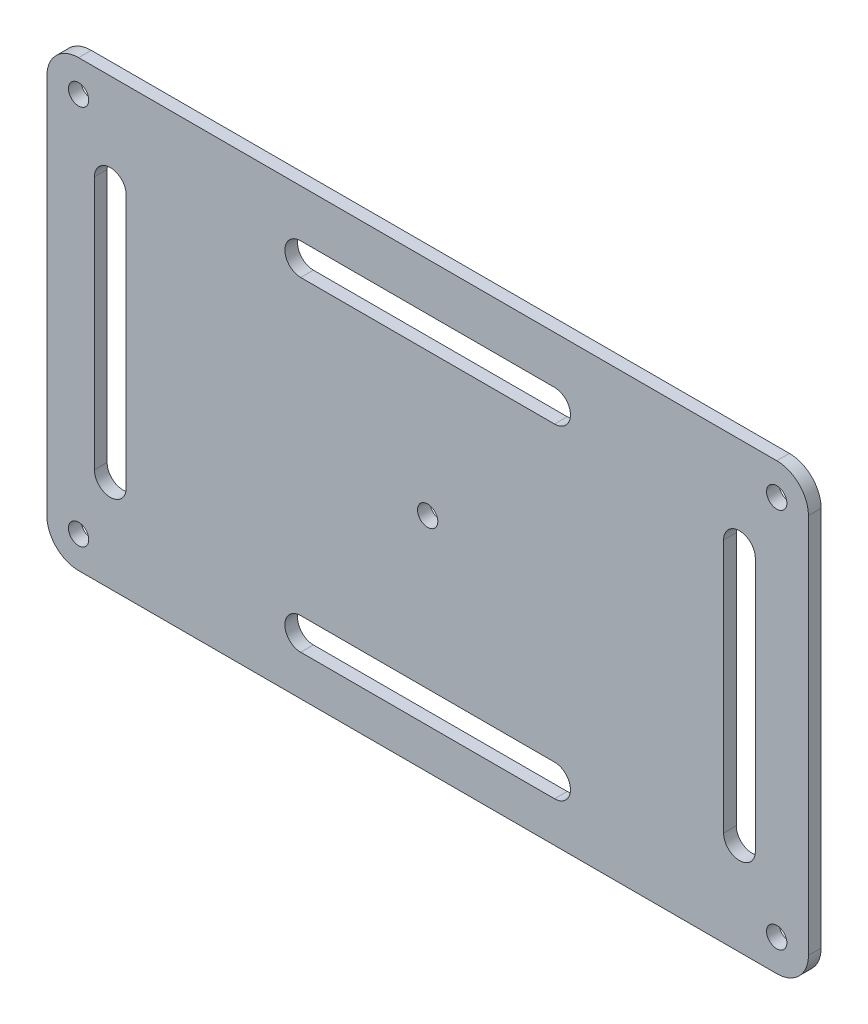
from build123d import *

# Parameters (mm, degrees)
SKETCH1_R           = 1.6
BOSS_EXTRUDE1_DEPTH = 2


with BuildPart() as part:
    # Sketch1 → Boss-Extrude1 (new body)
    with BuildSketch(Plane.XY):
        with BuildLine():
            Line((55, 35), (-55, 35))
            ThreePointArc((-55, 35), (-58.535533906, 33.535533906), (-60, 30))
            Line((-60, 30), (-60, -30))
            ThreePointArc((-60, -30), (-58.535533906, -33.535533906), (-55, -35))
            Line((-55, -35), (55, -35))
            ThreePointArc((55, -35), (58.535533906, -33.535533906), (60, -30))
            Line((60, -30), (60, 30))
            ThreePointArc((60, 30), (58.535533906, 33.535533906), (55, 35))
        make_face()
        with Locations((-55, 30)):
            Circle(SKETCH1_R, mode=Mode.SUBTRACT)
        with Locations((-55, -30)):
            Circle(SKETCH1_R, mode=Mode.SUBTRACT)
        with Locations((55, -30)):
            Circle(SKETCH1_R, mode=Mode.SUBTRACT)
        with Locations((55, 30)):
            Circle(SKETCH1_R, mode=Mode.SUBTRACT)
        Circle(SKETCH1_R, mode=Mode.SUBTRACT)
        with BuildLine():
            Line((-20, 27.5), (20, 27.5))
            ThreePointArc((20, 27.5), (22.5, 25), (20, 22.5))
            Line((20, 22.5), (-20, 22.5))
            ThreePointArc((-20, 22.5), (-22.5, 25), (-20, 27.5))
        make_face(mode=Mode.SUBTRACT)
        with BuildLine():
            Line((-47.5, 20), (-47.5, -20))
            ThreePointArc((-47.5, -20), (-50, -22.5), (-52.5, -20))
            Line((-52.5, -20), (-52.5, 20))
            ThreePointArc((-52.5, 20), (-50, 22.5), (-47.5, 20))
        make_face(mode=Mode.SUBTRACT)
        with BuildLine():
            Line((-20, -23.636211525), (20, -23.636211525))
            ThreePointArc((20, -23.636211525), (22.5, -26.136211525), (20, -28.636211525))
            Line((20, -28.636211525), (-20, -28.636211525))
            ThreePointArc((-20, -28.636211525), (-22.5, -26.136211525), (-20, -23.636211525))
        make_face(mode=Mode.SUBTRACT)
        with BuildLine():
            Line((51.628871571, 20), (51.628871571, -20))
            ThreePointArc((51.628871571, -20), (49.128871571, -22.5), (46.628871571, -20))
            Line((46.628871571, -20), (46.628871571, 20))
            ThreePointArc((46.628871571, 20), (49.128871571, 22.5), (51.628871571, 20))
        make_face(mode=Mode.SUBTRACT)
    extrude(amount=BOSS_EXTRUDE1_DEPTH)


solid = part.part
